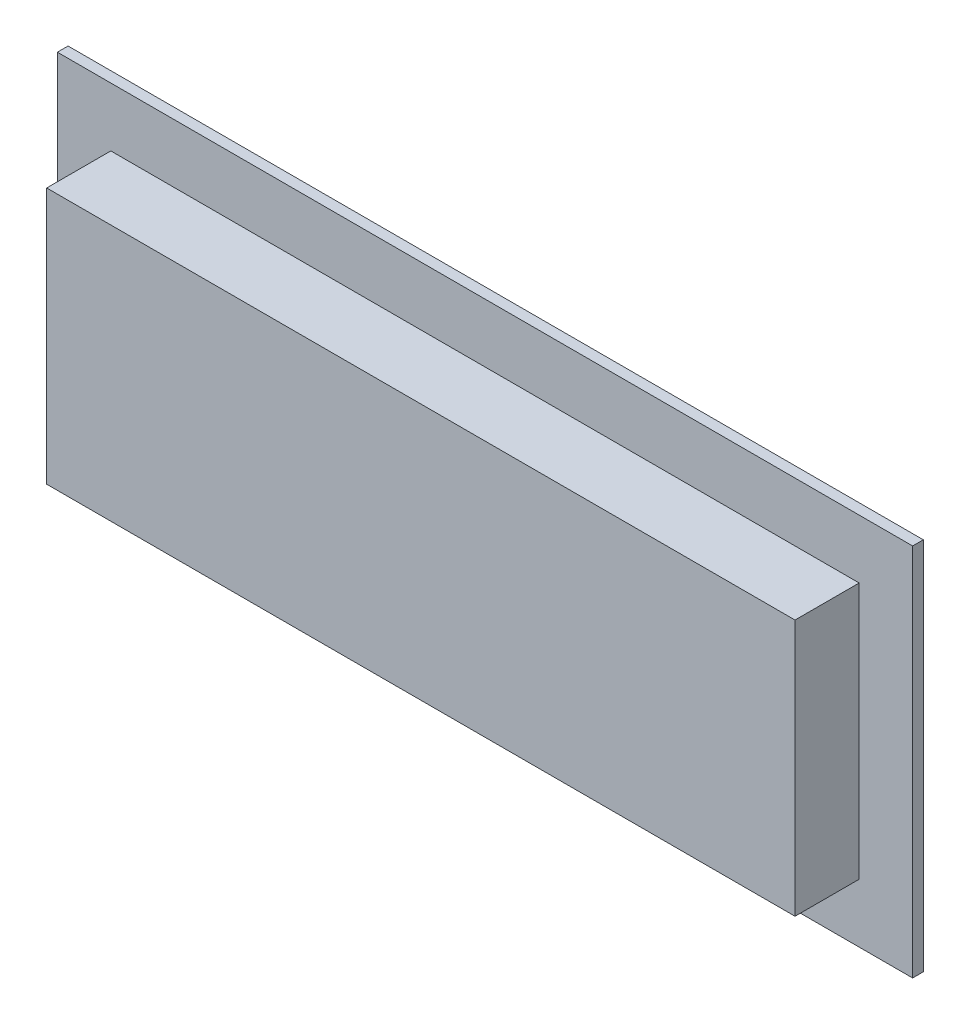
from build123d import *

# Parameters (mm, degrees)
SKETCH1_W           = 80
SKETCH1_H           = 35
BOSS_EXTRUDE1_DEPTH = 1
SKETCH2_W           = 70
SKETCH2_H           = 24
BOSS_EXTRUDE2_DEPTH = 6
SKETCH3_W           = 44.648131597
SKETCH3_H           = 14.861449517
BOSS_EXTRUDE3_DEPTH = 3
SKETCH4_W           = 2
SKETCH4_H           = 14.195770454
CUT_EXTRUDE1_DEPTH  = 77.228769639
SKETCH5_W           = 3.954548799
SKETCH5_H           = 8.674494139
BOSS_EXTRUDE4_DEPTH = 1


with BuildPart() as part:
    # Sketch1 → Boss-Extrude1 (new body)
    with BuildSketch(Plane.XY):
        Rectangle(SKETCH1_W, SKETCH1_H)
    extrude(amount=BOSS_EXTRUDE1_DEPTH)

    # Sketch2 → Boss-Extrude2 (add)
    with BuildSketch(Plane.XY.offset(1)):
        Rectangle(SKETCH2_W, SKETCH2_H)
    extrude(amount=BOSS_EXTRUDE2_DEPTH)

    # Sketch3 → Boss-Extrude3 (add)
    with BuildSketch(Plane(origin=(0, 0, 0), x_dir=(-1, 0, 0), z_dir=(0, 0, -1))):
        with Locations((-13.90470384, -7.430724759)):
            Rectangle(SKETCH3_W, SKETCH3_H)
    extrude(amount=BOSS_EXTRUDE3_DEPTH)

    # Sketch4 → Cut-Extrude1 (cut, through all)
    with BuildSketch(Plane(origin=(36.228769639, 0, 0), x_dir=(0, 0, -1), z_dir=(1, 0, 0))):
        with Locations((1, -6.56356429)):
            Rectangle(SKETCH4_W, SKETCH4_H)
    extrude(amount=-CUT_EXTRUDE1_DEPTH, mode=Mode.SUBTRACT)

    # Sketch5 → Boss-Extrude4 (add)
    with BuildSketch(Plane(origin=(0, 0, -3), x_dir=(-1, 0, 0), z_dir=(0, 0, -1))):
        with Locations((-14.096052976, -7.845314553)):
            Rectangle(SKETCH5_W, SKETCH5_H)
    extrude(amount=BOSS_EXTRUDE4_DEPTH)


solid = part.part
